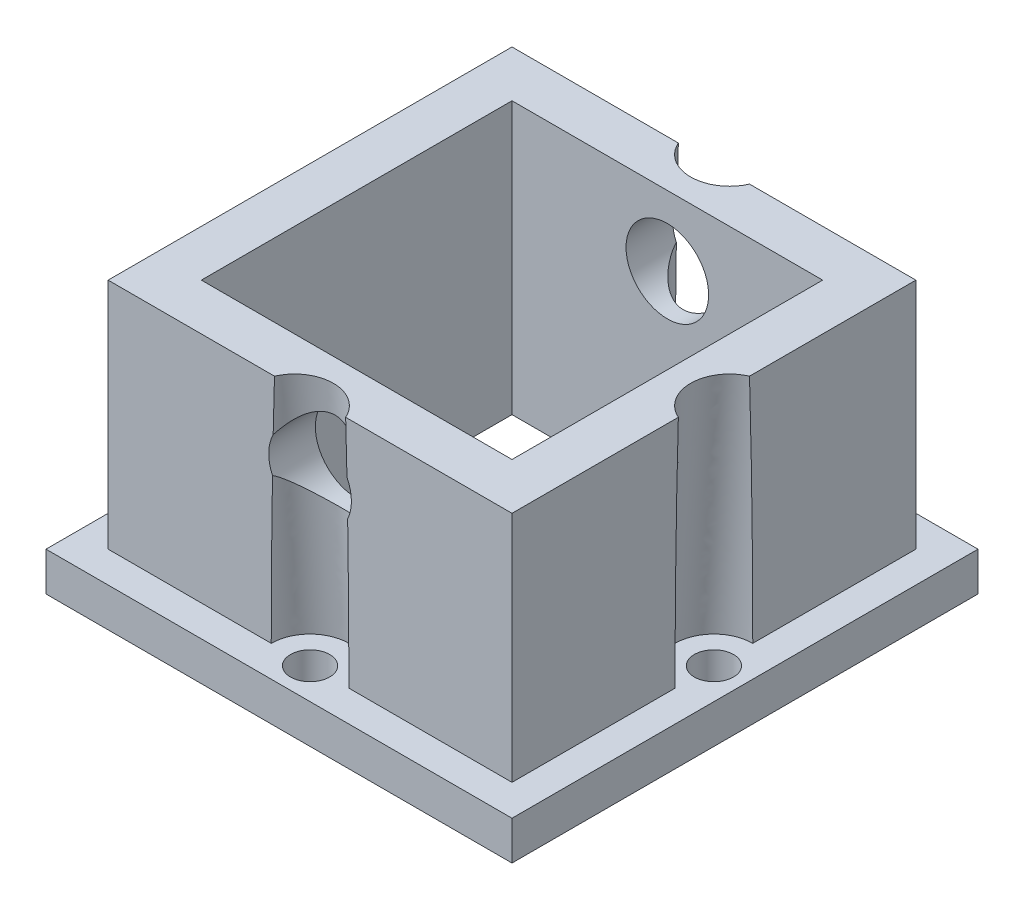
from build123d import *

# Parameters (mm, degrees)
SKETCH1_W           = 38.1
SKETCH1_H           = 38.1
BOSS_EXTRUDE1_DEPTH = 3.175
SKETCH2_W           = 33.02
SKETCH2_H           = 33.02
BOSS_EXTRUDE2_DEPTH = 19.05
SKETCH3_W           = 25.4
SKETCH3_H           = 25.4
CUT_EXTRUDE1_DEPTH  = 23.225
SKETCH4_R           = 1.6002
CUT_EXTRUDE2_DEPTH  = 4.175
CIRPATTERN1_COUNT   = 4
SKETCH6_R           = 3.3782
CUT_EXTRUDE4_DEPTH  = 36.56
SKETCH10_R          = 3.175
CIRPATTERN3_COUNT   = 4


with BuildPart() as part:
    # Sketch1 → Boss-Extrude1 (new body)
    with BuildSketch(Plane(origin=(0, 0, 0), x_dir=(1, 0, 0), z_dir=(0, 1, 0))):
        Rectangle(SKETCH1_W, SKETCH1_H)
    extrude(amount=BOSS_EXTRUDE1_DEPTH)

    # Sketch2 → Boss-Extrude2 (add)
    with BuildSketch(Plane(origin=(0, 3.175, 0), x_dir=(1, 0, 0), z_dir=(0, 1, 0))):
        Rectangle(SKETCH2_W, SKETCH2_H)
    extrude(amount=BOSS_EXTRUDE2_DEPTH)

    # Sketch3 → Cut-Extrude1 (cut, through all)
    with BuildSketch(Plane(origin=(0, 22.225, 0), x_dir=(1, 0, 0), z_dir=(0, 1, 0))):
        Rectangle(SKETCH3_W, SKETCH3_H)
    extrude(amount=-CUT_EXTRUDE1_DEPTH, mode=Mode.SUBTRACT)

    # Sketch4 → Cut-Extrude2 (cut, through all)
    with BuildSketch(Plane(origin=(0, 3.175, 0), x_dir=(1, 0, 0), z_dir=(0, 1, 0))):
        with Locations((16.51, 0)):
            Circle(SKETCH4_R)
    cut_extrude2 = extrude(amount=-CUT_EXTRUDE2_DEPTH, mode=Mode.SUBTRACT)

    # CirPattern1: Cut-Extrude2 ×4 about axis, 1 skipped
    cirpattern1_axis = Axis((0, 0, 0), (0, 1, 0))
    add([cut_extrude2.rotate(cirpattern1_axis, i * 360 / CIRPATTERN1_COUNT) for i in range(1, CIRPATTERN1_COUNT) if i not in (2,)], mode=Mode.SUBTRACT)

    # Sketch6 → Cut-Extrude4 (cut, through all)
    with BuildSketch(Plane(origin=(0, 0, -16.51), x_dir=(-1, 0, 0), z_dir=(0, 0, -1))):
        with Locations((0, 16.51)):
            Circle(SKETCH6_R)
    extrude(amount=-CUT_EXTRUDE4_DEPTH, mode=Mode.SUBTRACT)

    # Cut-Sweep2: sweep along a path in Sketch9
    with BuildLine(Plane.XY) as cut_sweep2_path:
        Line((16.51, 3.175), (17.78, 22.225))
    # Sketch10 → Cut-Sweep2 (sweep, cut)
    with BuildSketch(Plane(origin=(0, 3.175, 0), x_dir=(1, 0, 0), z_dir=(0, 1, 0))):
        with Locations((16.51, 0)):
            Circle(SKETCH10_R)
    cut_sweep2 = sweep(path=cut_sweep2_path.line, mode=Mode.SUBTRACT)

    # CirPattern3: Cut-Sweep2 ×4 about axis, 1 skipped
    cirpattern3_axis = Axis((0, -1.42875, 0), (0, 1, 0))
    add([cut_sweep2.rotate(cirpattern3_axis, i * 360 / CIRPATTERN3_COUNT) for i in range(1, CIRPATTERN3_COUNT) if i not in (2,)], mode=Mode.SUBTRACT)


solid = part.part
